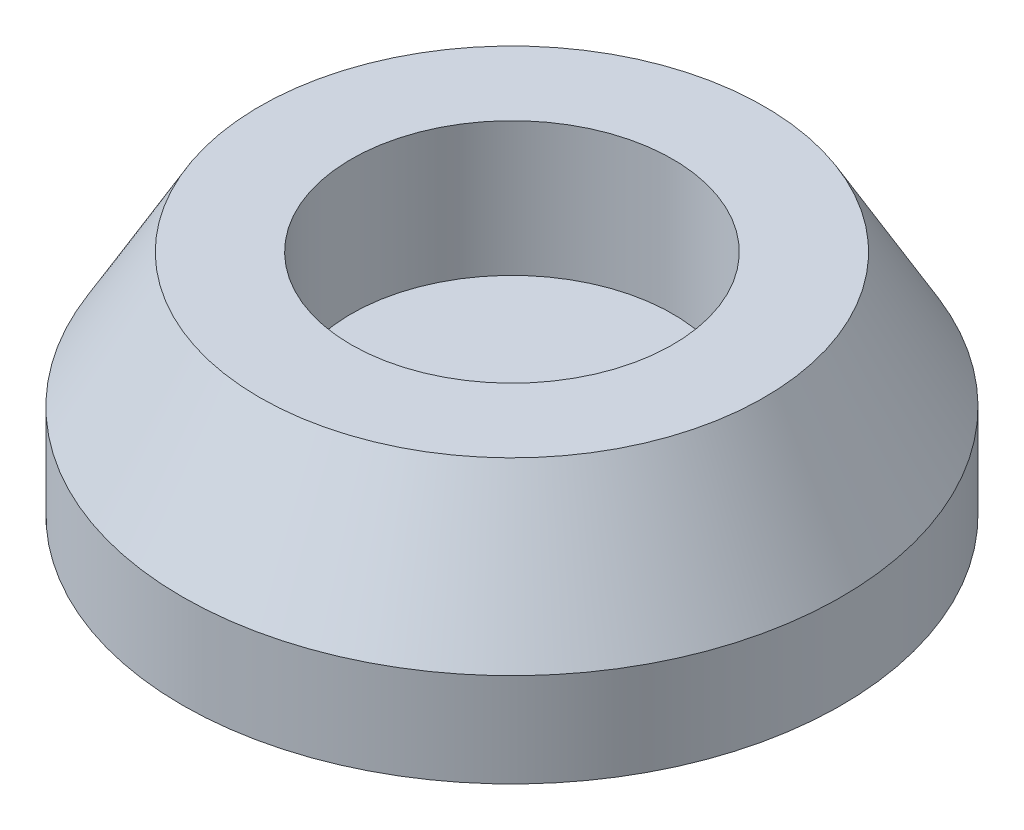
from build123d import *

# Parameters (mm, degrees)
SKETCH1_R           = 12.3
BOSS_EXTRUDE1_DEPTH = 3.5
SKETCH2_R           = 12.3
SKETCH2_R_2         = 6
BOSS_EXTRUDE2_DEPTH = 5
CHAMFER1_SIZE       = 5
CHAMFER1_SIZE2      = 2.886751346


with BuildPart() as part:
    # Sketch1 → Boss-Extrude1 (new body)
    with BuildSketch(Plane(origin=(0, 0, 0), x_dir=(1, 0, 0), z_dir=(0, 1, 0))):
        Circle(SKETCH1_R)
    extrude(amount=BOSS_EXTRUDE1_DEPTH)

    # Sketch2 → Boss-Extrude2 (add)
    with BuildSketch(Plane(origin=(0, 3.5, 0), x_dir=(1, 0, 0), z_dir=(0, 1, 0))):
        Circle(SKETCH2_R)
        Circle(SKETCH2_R_2, mode=Mode.SUBTRACT)
    extrude(amount=BOSS_EXTRUDE2_DEPTH)

    # Chamfer1
    chamfer1_edges = [part.edges().sort_by_distance(p)[0] for p in [
        (-12.3, 8.5, 0),
    ]]
    chamfer1_side = [part.faces().sort_by_distance(p)[0] for p in [
        (-12.3, 4.25, 0),
    ]]
    chamfer(chamfer1_edges, length=CHAMFER1_SIZE, length2=CHAMFER1_SIZE2, reference=chamfer1_side[0])


solid = part.part
